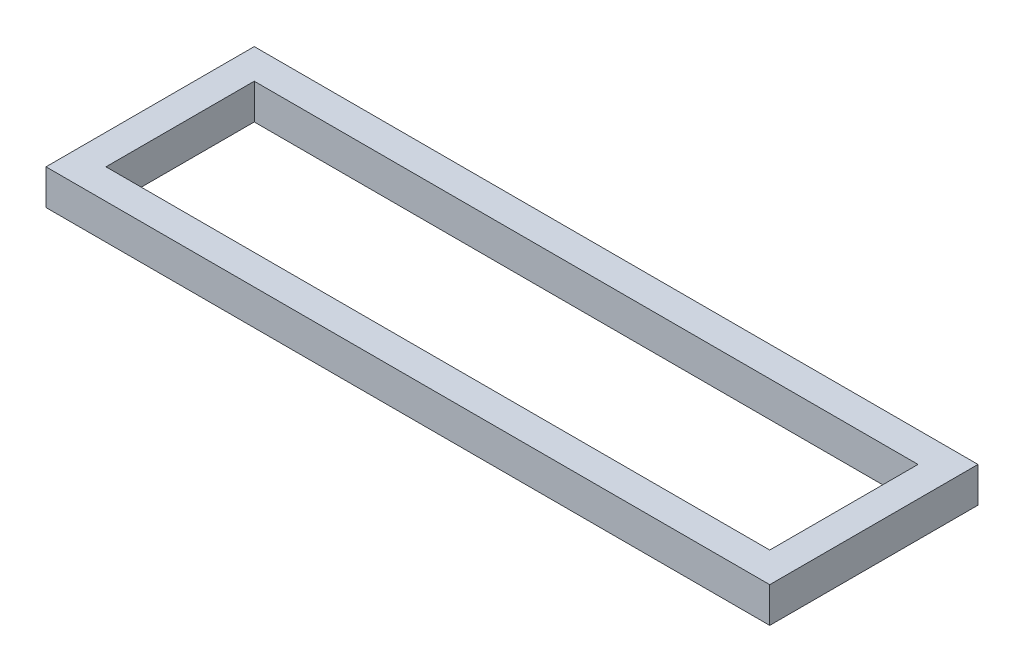
from build123d import *

# Parameters (mm, degrees)
CROQUIS1_W              = 976.25
CROQUIS1_H              = 280.925
CROQUIS1_W_2            = 895.35
CROQUIS1_H_2            = 200.025
SALIENTE_EXTRUIR1_DEPTH = 47.625


with BuildPart() as part:
    # Croquis1 → Saliente-Extruir1 (new body)
    with BuildSketch(Plane(origin=(0, 0, 0), x_dir=(1, 0, 0), z_dir=(0, 1, 0))):
        Rectangle(CROQUIS1_W, CROQUIS1_H)
        Rectangle(CROQUIS1_W_2, CROQUIS1_H_2, mode=Mode.SUBTRACT)
    extrude(amount=SALIENTE_EXTRUIR1_DEPTH)


solid = part.part
